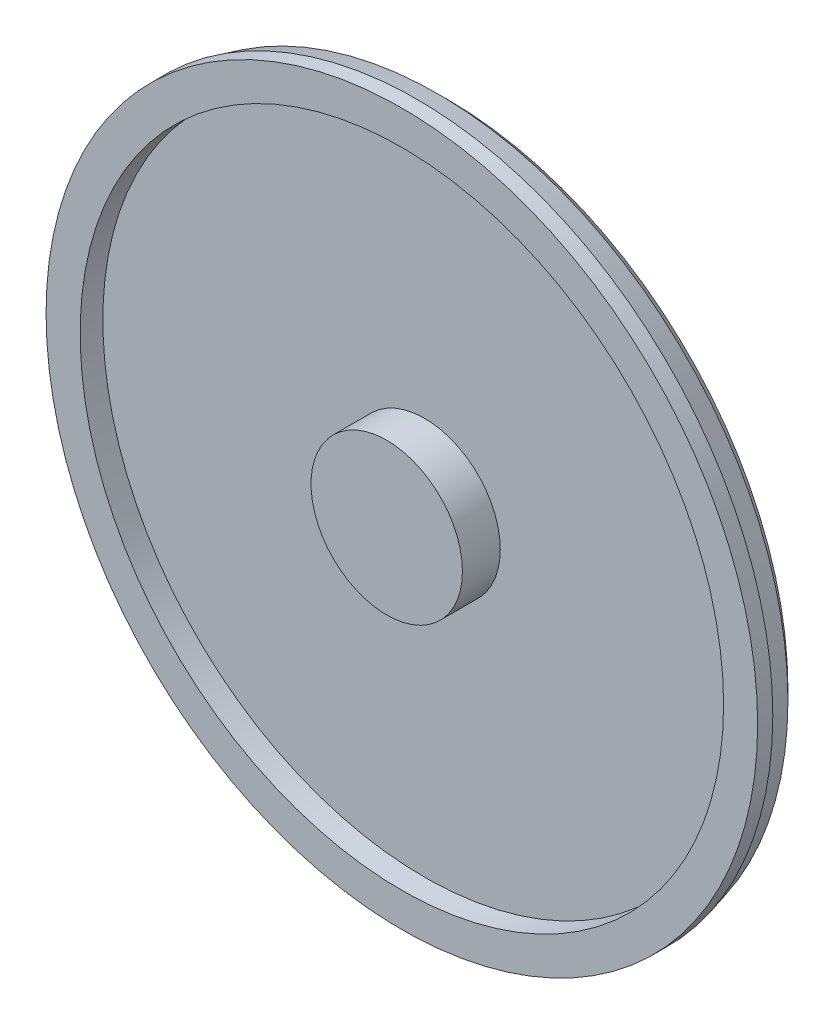
from build123d import *

# Parameters (mm, degrees)
SKETCH2_R           = 470
BOSS_EXTRUDE1_DEPTH = 60
BOSS_EXTRUDE2_START = -60
SKETCH3_R           = 100
BOSS_EXTRUDE2_DEPTH = 80
SKETCH4_R           = 425
SKETCH4_R_2         = 100
CUT_EXTRUDE2_DEPTH  = 30
CHAMFER2_SIZE       = 20
CHAMFER8_SIZE       = 20
CHAMFER8_SIZE2      = 10.352761804


with BuildPart() as part:
    # Sketch2 → Boss-Extrude1 (new body)
    with BuildSketch(Plane.XY):
        Circle(SKETCH2_R)
    extrude(amount=BOSS_EXTRUDE1_DEPTH)

    # Sketch3 → Boss-Extrude2 (add)
    with BuildSketch(Plane.XY.offset(60).offset(BOSS_EXTRUDE2_START)):
        Circle(SKETCH3_R)
    extrude(amount=BOSS_EXTRUDE2_DEPTH)

    # Sketch4 → Cut-Extrude2 (cut)
    with BuildSketch(Plane.XY.offset(60)):
        Circle(SKETCH4_R)
        Circle(SKETCH4_R_2, mode=Mode.SUBTRACT)
    extrude(amount=-CUT_EXTRUDE2_DEPTH, mode=Mode.SUBTRACT)

    # Chamfer2
    chamfer2_edges = [part.edges().sort_by_distance(p)[0] for p in [
        (-470, 0, 0),
    ]]
    chamfer(chamfer2_edges, length=CHAMFER2_SIZE)

    # Chamfer8
    chamfer8_edges = [part.edges().sort_by_distance(p)[0] for p in [
        (-470, 0, 20),
    ]]
    chamfer8_side = [part.faces().sort_by_distance(p)[0] for p in [
        (-470, 0, 40),
    ]]
    chamfer(chamfer8_edges, length=CHAMFER8_SIZE, length2=CHAMFER8_SIZE2, reference=chamfer8_side[0])


solid = part.part
